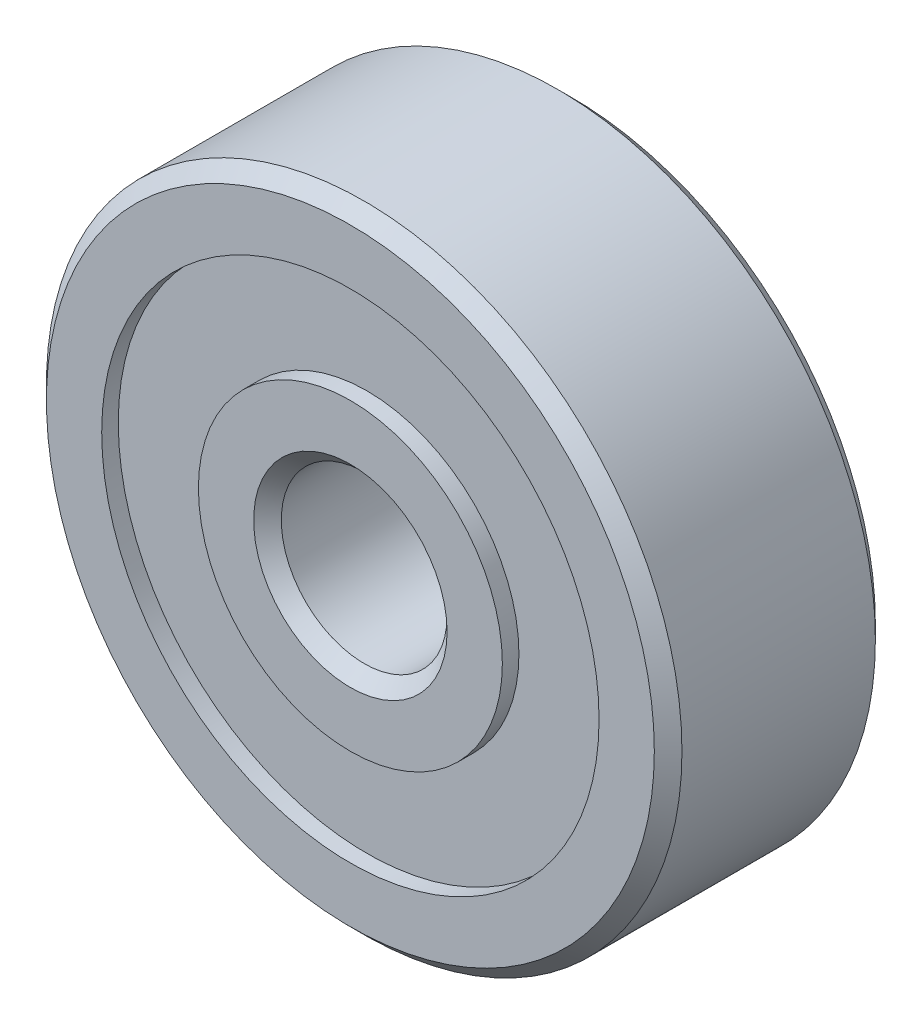
from build123d import *

# Parameters (mm, degrees)
SKETCH1_R           = 5.75
SKETCH1_R_2         = 1.5
BOSS_EXTRUDE1_DEPTH = 2
CHAMFER1_SIZE       = 0.25
SKETCH2_W           = 1.75
SKETCH2_H           = 0.3


with BuildPart() as part:
    # Sketch1 → Boss-Extrude1 (new body, symmetric)
    with BuildSketch(Plane.XY):
        Circle(SKETCH1_R)
        Circle(SKETCH1_R_2, mode=Mode.SUBTRACT)
    extrude(amount=BOSS_EXTRUDE1_DEPTH, both=True)

    # Chamfer1
    chamfer1_edges = [part.edges().sort_by_distance(p)[0] for p in [
        (-5.75, 0, -2),
        (-5.75, 0, 2),
        (-1.5, 0, -2),
        (-1.5, 0, 2),
    ]]
    chamfer(chamfer1_edges, length=CHAMFER1_SIZE)

    # Sketch2 → Cut-Revolve1 (revolve, cut)
    with BuildSketch(Plane(origin=(0, 0, 0), x_dir=(1, 0, 0), z_dir=(0, 1, 0))):
        with Locations((-3.625, -1.85)):
            Rectangle(SKETCH2_W, SKETCH2_H)
    cut_revolve1 = revolve(axis=Axis((0, 0, 0), (0, 0, -1)), mode=Mode.SUBTRACT)

    # Mirror1: Cut-Revolve1 across plane
    add(cut_revolve1.mirror(Plane.XY), mode=Mode.SUBTRACT)


solid = part.part
